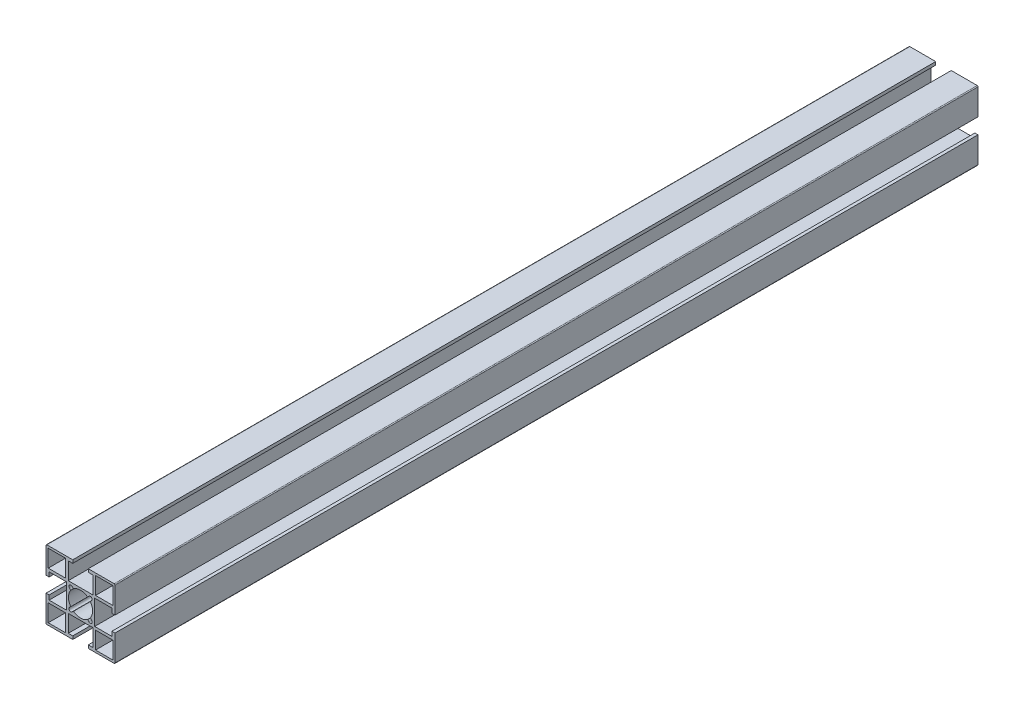
from build123d import *

# Parameters (mm, degrees)
SKETCH114_W               = 10
SKETCH114_H               = 10
F_40_X_40A_X_R0_5_1_DEPTH = 500


with BuildPart() as part:
    # Sketch114 → 铝型材 40 X 40A X R0.5(1) (new body)
    with BuildSketch(Plane.YX):
        with BuildLine():
            Line((-19.5, 20), (-4.5, 20))
            Line((-4.5, 20), (-4.5, 18.2))
            Line((-4.5, 18.2), (-7.1, 18.2))
            Line((-7.1, 18.2), (-7.1, 8.2))
            Line((-7.1, 8.2), (7.1, 8.2))
            Line((7.1, 8.2), (7.1, 18.2))
            Line((7.1, 18.2), (4.5, 18.2))
            Line((4.5, 18.2), (4.5, 20))
            Line((4.5, 20), (19.5, 20))
            ThreePointArc((19.5, 20), (19.853553391, 19.853553391), (20, 19.5))
            Line((20, 19.5), (20, 4.5))
            Line((20, 4.5), (18.2, 4.5))
            Line((18.2, 4.5), (18.2, 7.1))
            Line((18.2, 7.1), (8.2, 7.1))
            Line((8.2, 7.1), (8.2, -7.1))
            Line((8.2, -7.1), (18.2, -7.1))
            Line((18.2, -7.1), (18.2, -4.5))
            Line((18.2, -4.5), (20, -4.5))
            Line((20, -4.5), (20, -19.5))
            ThreePointArc((20, -19.5), (19.853553391, -19.853553391), (19.5, -20))
            Line((19.5, -20), (4.5, -20))
            Line((4.5, -20), (4.5, -18.2))
            Line((4.5, -18.2), (7.1, -18.2))
            Line((7.1, -18.2), (7.1, -8.2))
            Line((7.1, -8.2), (-7.1, -8.2))
            Line((-7.1, -8.2), (-7.1, -18.2))
            Line((-7.1, -18.2), (-4.5, -18.2))
            Line((-4.5, -18.2), (-4.5, -20))
            Line((-4.5, -20), (-19.5, -20))
            ThreePointArc((-19.5, -20), (-19.853553391, -19.853553391), (-20, -19.5))
            Line((-20, -19.5), (-20, -4.5))
            Line((-20, -4.5), (-18.2, -4.5))
            Line((-18.2, -4.5), (-18.2, -7.1))
            Line((-18.2, -7.1), (-8.2, -7.1))
            Line((-8.2, -7.1), (-8.2, 7.1))
            Line((-8.2, 7.1), (-18.2, 7.1))
            Line((-18.2, 7.1), (-18.2, 4.5))
            Line((-18.2, 4.5), (-20, 4.5))
            Line((-20, 4.5), (-20, 19.5))
            ThreePointArc((-20, 19.5), (-19.853553391, 19.853553391), (-19.5, 20))
        make_face()
        with BuildLine():
            Line((-4.87903679, 6.434671709), (-4.110433762, 5.66606868))
            ThreePointArc((-4.110433762, 5.66606868), (0, 7), (4.110433762, 5.66606868))
            Line((4.110433762, 5.66606868), (4.87903679, 6.434671709))
            ThreePointArc((4.87903679, 6.434671709), (6.434671709, 6.434671709), (6.434671709, 4.87903679))
            Line((6.434671709, 4.87903679), (5.66606868, 4.110433762))
            ThreePointArc((5.66606868, 4.110433762), (7, 0), (5.66606868, -4.110433762))
            Line((5.66606868, -4.110433762), (6.434671709, -4.87903679))
            ThreePointArc((6.434671709, -4.87903679), (6.434671709, -6.434671709), (4.87903679, -6.434671709))
            Line((4.87903679, -6.434671709), (4.110433762, -5.66606868))
            ThreePointArc((4.110433762, -5.66606868), (0, -7), (-4.110433762, -5.66606868))
            Line((-4.110433762, -5.66606868), (-4.87903679, -6.434671709))
            ThreePointArc((-4.87903679, -6.434671709), (-6.434671709, -6.434671709), (-6.434671709, -4.87903679))
            Line((-6.434671709, -4.87903679), (-5.66606868, -4.110433762))
            ThreePointArc((-5.66606868, -4.110433762), (-7, 0), (-5.66606868, 4.110433762))
            Line((-5.66606868, 4.110433762), (-6.434671709, 4.87903679))
            ThreePointArc((-6.434671709, 4.87903679), (-6.434671709, 6.434671709), (-4.87903679, 6.434671709))
        make_face(mode=Mode.SUBTRACT)
        with Locations((-13.7, 13.7)):
            Rectangle(SKETCH114_W, SKETCH114_H, mode=Mode.SUBTRACT)
        with Locations((13.7, 13.7)):
            Rectangle(SKETCH114_W, SKETCH114_H, mode=Mode.SUBTRACT)
        with Locations((13.7, -13.7)):
            Rectangle(SKETCH114_W, SKETCH114_H, mode=Mode.SUBTRACT)
        with Locations((-13.7, -13.7)):
            Rectangle(SKETCH114_W, SKETCH114_H, mode=Mode.SUBTRACT)
    extrude(amount=F_40_X_40A_X_R0_5_1_DEPTH)


solid = part.part
